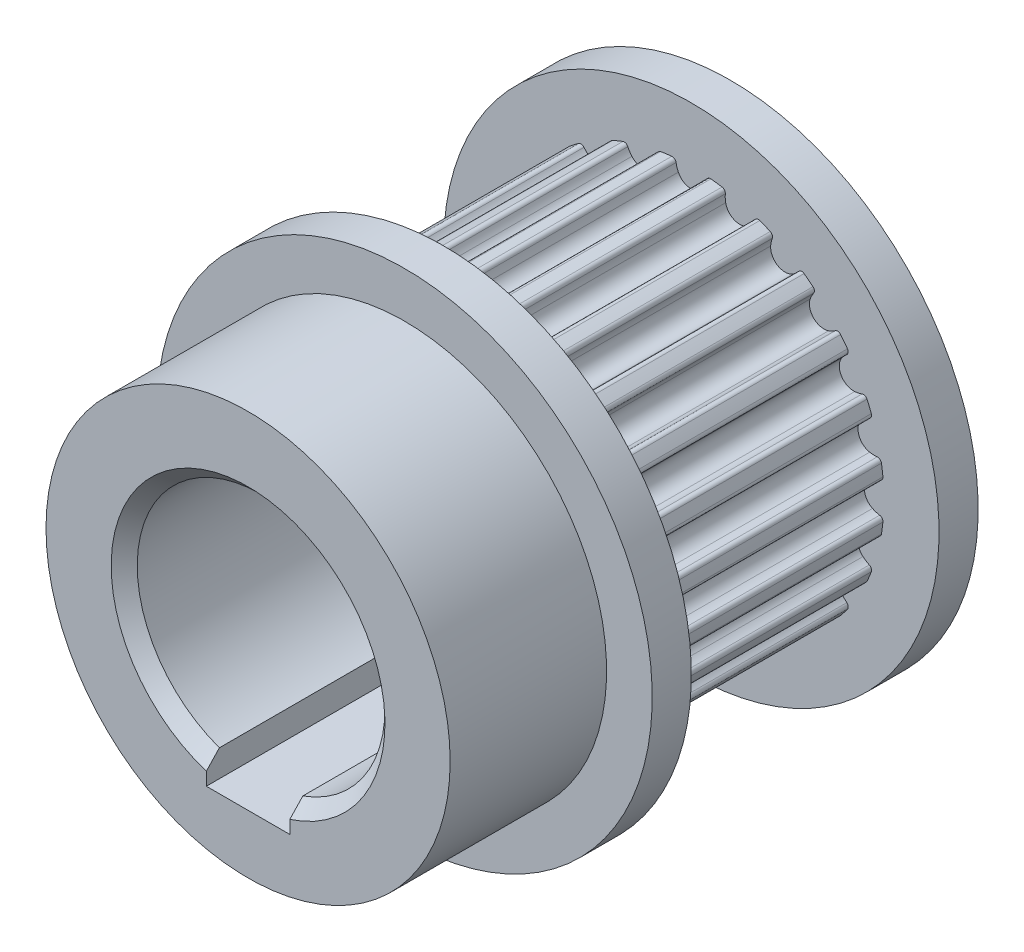
from build123d import *

# Parameters (mm, degrees)
BOSS_EXTRUDE1_DEPTH = 9.5
CUT_EXTRUDE1_DEPTH  = 9.5
SKETCH4_R           = 4.75
CUT_EXTRUDE2_DEPTH  = 15.079684088
SKETCH6_R           = 9.5
SKETCH6_R_2         = 4.75
BOSS_EXTRUDE2_DEPTH = 1.5
BOSS_EXTRUDE4_START = -9.5
SKETCH6_3_R         = 9.5
SKETCH6_3_R_2       = 4.75
BOSS_EXTRUDE4_DEPTH = 1.5
SKETCH7_R           = 7.75
SKETCH7_R_2         = 4.75
BOSS_EXTRUDE5_DEPTH = 6
SKETCH9_W           = 3.2
SKETCH9_H           = 5.5
CUT_EXTRUDE3_DEPTH  = 23.86372673
CHAMFER1_SIZE       = 0.5


with BuildPart() as part:
    # Sketch1 → Boss-Extrude1 (new body)
    with BuildSketch(Plane.XY):
        with BuildLine():
            ThreePointArc((-0.749859573, 7.347268932), (0, -7.385435), (0.749859573, 7.347268932))
            ThreePointArc((0.749859573, 7.347268932), (0.643529079, 7.317210656), (0.586634557, 7.222486386))
            ThreePointArc((0.586634557, 7.222486386), (0.55274815, 7.081673642), (0.498876404, 6.947232753))
            ThreePointArc((0.498876404, 6.947232753), (0, 6.635435), (-0.498876404, 6.947232753))
            ThreePointArc((-0.498876404, 6.947232753), (-0.55274815, 7.081673642), (-0.586634557, 7.222486386))
            ThreePointArc((-0.586634557, 7.222486386), (-0.643529079, 7.317210656), (-0.749859573, 7.347268932))
        make_face()
    extrude(amount=BOSS_EXTRUDE1_DEPTH)

    # Sketch2 → Cut-Extrude1 (cut)
    with BuildSketch(Plane.XY.offset(9.5)):
        with BuildLine():
            ThreePointArc((-1.30267156, 7.128218326), (-1.272232117, 7.234440331), (-1.177304402, 7.290994753))
            ThreePointArc((-1.177304402, 7.290994753), (-1.911491234, 7.133782405), (-2.625921857, 6.902838876))
            ThreePointArc((-2.625921857, 6.902838876), (-2.515434832, 6.901325167), (-2.435962499, 6.824553935))
            ThreePointArc((-2.435962499, 6.824553935), (-2.366785723, 6.697309716), (-2.27995375, 6.581392823))
            ThreePointArc((-2.27995375, 6.581392823), (-1.717376951, 6.409338035), (-1.316198544, 6.839630252))
            ThreePointArc((-1.316198544, 6.839630252), (-1.298958296, 6.983433212), (-1.30267156, 7.128218326))
        make_face()
        with BuildLine():
            ThreePointArc((2.625921857, 6.902838876), (1.911491234, 7.133782405), (1.177304402, 7.290994753))
            ThreePointArc((1.177304402, 7.290994753), (1.272232117, 7.234440331), (1.30267156, 7.128218326))
            ThreePointArc((1.30267156, 7.128218326), (1.298958296, 6.983433212), (1.316198544, 6.839630252))
            ThreePointArc((1.316198544, 6.839630252), (1.717376951, 6.409338035), (2.27995375, 6.581392823))
            ThreePointArc((2.27995375, 6.581392823), (2.366785723, 6.697309716), (2.435962499, 6.824553935))
            ThreePointArc((2.435962499, 6.824553935), (2.515434832, 6.901325167), (2.625921857, 6.902838876))
        make_face()
        with BuildLine():
            ThreePointArc((4.323031905, 5.987991757), (3.6927175, 6.395974328), (3.024237027, 6.73785133))
            ThreePointArc((3.024237027, 6.73785133), (3.101292798, 6.658654852), (3.103202764, 6.548173968))
            ThreePointArc((3.103202764, 6.548173968), (3.062142881, 6.40928335), (3.041576737, 6.265918252))
            ThreePointArc((3.041576737, 6.265918252), (3.3177175, 5.746455275), (3.905656016, 5.767041848))
            ThreePointArc((3.905656016, 5.767041848), (4.019530761, 5.8565352), (4.119283622, 5.96153941))
            ThreePointArc((4.119283622, 5.96153941), (4.215917859, 6.015125773), (4.323031905, 5.987991757))
        make_face()
        with BuildLine():
            ThreePointArc((5.725534474, 4.665072896), (5.222291171, 5.222291171), (4.665072896, 5.725534474))
            ThreePointArc((4.665072896, 5.725534474), (4.719005499, 5.62909305), (4.692255827, 5.521882374))
            ThreePointArc((4.692255827, 5.521882374), (4.616647489, 5.398351419), (4.559676501, 5.265194279))
            ThreePointArc((4.559676501, 5.265194279), (4.691961085, 4.691961085), (5.265194279, 4.559676501))
            ThreePointArc((5.265194279, 4.559676501), (5.398351419, 4.616647489), (5.521882374, 4.692255827))
            ThreePointArc((5.521882374, 4.692255827), (5.62909305, 4.719005499), (5.725534474, 4.665072896))
        make_face()
        with BuildLine():
            ThreePointArc((6.73785133, 3.024237027), (6.395974328, 3.6927175), (5.987991757, 4.323031905))
            ThreePointArc((5.987991757, 4.323031905), (6.015125773, 4.215917859), (5.96153941, 4.119283622))
            ThreePointArc((5.96153941, 4.119283622), (5.8565352, 4.019530761), (5.767041848, 3.905656016))
            ThreePointArc((5.767041848, 3.905656016), (5.746455275, 3.3177175), (6.265918252, 3.041576737))
            ThreePointArc((6.265918252, 3.041576737), (6.40928335, 3.062142881), (6.548173968, 3.103202764))
            ThreePointArc((6.548173968, 3.103202764), (6.658654852, 3.101292798), (6.73785133, 3.024237027))
        make_face()
        with BuildLine():
            ThreePointArc((7.290994753, 1.177304402), (7.133782405, 1.911491234), (6.902838876, 2.625921857))
            ThreePointArc((6.902838876, 2.625921857), (6.901325167, 2.515434832), (6.824553935, 2.435962499))
            ThreePointArc((6.824553935, 2.435962499), (6.697309716, 2.366785723), (6.581392823, 2.27995375))
            ThreePointArc((6.581392823, 2.27995375), (6.409338035, 1.717376951), (6.839630252, 1.316198544))
            ThreePointArc((6.839630252, 1.316198544), (6.983433212, 1.298958296), (7.128218326, 1.30267156))
            ThreePointArc((7.128218326, 1.30267156), (7.234440331, 1.272232117), (7.290994753, 1.177304402))
        make_face()
        with BuildLine():
            ThreePointArc((7.385435, 0), (7.375887312, 0.375415113), (7.347268932, 0.749859573))
            ThreePointArc((7.347268932, 0.749859573), (7.317210656, 0.643529079), (7.222486386, 0.586634557))
            ThreePointArc((7.222486386, 0.586634557), (7.081673642, 0.55274815), (6.947232753, 0.498876404))
            ThreePointArc((6.947232753, 0.498876404), (6.635435, 0), (6.947232753, -0.498876404))
            ThreePointArc((6.947232753, -0.498876404), (7.081673642, -0.55274815), (7.222486386, -0.586634557))
            ThreePointArc((7.222486386, -0.586634557), (7.317210656, -0.643529079), (7.347268932, -0.749859573))
            ThreePointArc((7.347268932, -0.749859573), (7.375887312, -0.375415113), (7.385435, 0))
        make_face()
        with BuildLine():
            ThreePointArc((6.902838876, -2.625921857), (7.133782405, -1.911491234), (7.290994753, -1.177304402))
            ThreePointArc((7.290994753, -1.177304402), (7.234440331, -1.272232117), (7.128218326, -1.30267156))
            ThreePointArc((7.128218326, -1.30267156), (6.983433212, -1.298958296), (6.839630252, -1.316198544))
            ThreePointArc((6.839630252, -1.316198544), (6.409338035, -1.717376951), (6.581392823, -2.27995375))
            ThreePointArc((6.581392823, -2.27995375), (6.697309716, -2.366785723), (6.824553935, -2.435962499))
            ThreePointArc((6.824553935, -2.435962499), (6.901325167, -2.515434832), (6.902838876, -2.625921857))
        make_face()
        with BuildLine():
            ThreePointArc((5.987991757, -4.323031905), (6.395974328, -3.6927175), (6.73785133, -3.024237027))
            ThreePointArc((6.73785133, -3.024237027), (6.658654852, -3.101292798), (6.548173968, -3.103202764))
            ThreePointArc((6.548173968, -3.103202764), (6.40928335, -3.062142881), (6.265918252, -3.041576737))
            ThreePointArc((6.265918252, -3.041576737), (5.746455275, -3.3177175), (5.767041848, -3.905656016))
            ThreePointArc((5.767041848, -3.905656016), (5.8565352, -4.019530761), (5.96153941, -4.119283622))
            ThreePointArc((5.96153941, -4.119283622), (6.015125773, -4.215917859), (5.987991757, -4.323031905))
        make_face()
        with BuildLine():
            ThreePointArc((4.665072896, -5.725534474), (5.222291171, -5.222291171), (5.725534474, -4.665072896))
            ThreePointArc((5.725534474, -4.665072896), (5.62909305, -4.719005499), (5.521882374, -4.692255827))
            ThreePointArc((5.521882374, -4.692255827), (5.398351419, -4.616647489), (5.265194279, -4.559676501))
            ThreePointArc((5.265194279, -4.559676501), (4.691961085, -4.691961085), (4.559676501, -5.265194279))
            ThreePointArc((4.559676501, -5.265194279), (4.616647489, -5.398351419), (4.692255827, -5.521882374))
            ThreePointArc((4.692255827, -5.521882374), (4.719005499, -5.62909305), (4.665072896, -5.725534474))
        make_face()
        with BuildLine():
            ThreePointArc((3.024237027, -6.73785133), (3.6927175, -6.395974328), (4.323031905, -5.987991757))
            ThreePointArc((4.323031905, -5.987991757), (4.215917859, -6.015125773), (4.119283622, -5.96153941))
            ThreePointArc((4.119283622, -5.96153941), (4.019530761, -5.8565352), (3.905656016, -5.767041848))
            ThreePointArc((3.905656016, -5.767041848), (3.3177175, -5.746455275), (3.041576737, -6.265918252))
            ThreePointArc((3.041576737, -6.265918252), (3.062142881, -6.40928335), (3.103202764, -6.548173968))
            ThreePointArc((3.103202764, -6.548173968), (3.101292798, -6.658654852), (3.024237027, -6.73785133))
        make_face()
        with BuildLine():
            ThreePointArc((1.177304402, -7.290994753), (1.911491234, -7.133782405), (2.625921857, -6.902838876))
            ThreePointArc((2.625921857, -6.902838876), (2.515434832, -6.901325167), (2.435962499, -6.824553935))
            ThreePointArc((2.435962499, -6.824553935), (2.366785723, -6.697309716), (2.27995375, -6.581392823))
            ThreePointArc((2.27995375, -6.581392823), (1.717376951, -6.409338035), (1.316198544, -6.839630252))
            ThreePointArc((1.316198544, -6.839630252), (1.298958296, -6.983433212), (1.30267156, -7.128218326))
            ThreePointArc((1.30267156, -7.128218326), (1.272232117, -7.234440331), (1.177304402, -7.290994753))
        make_face()
        with BuildLine():
            ThreePointArc((-0.586634557, -7.222486386), (-0.643529079, -7.317210656), (-0.749859573, -7.347268932))
            ThreePointArc((-0.749859573, -7.347268932), (0, -7.385435), (0.749859573, -7.347268932))
            ThreePointArc((0.749859573, -7.347268932), (0.643529079, -7.317210656), (0.586634557, -7.222486386))
            ThreePointArc((0.586634557, -7.222486386), (0.55274815, -7.081673642), (0.498876404, -6.947232753))
            ThreePointArc((0.498876404, -6.947232753), (0, -6.635435), (-0.498876404, -6.947232753))
            ThreePointArc((-0.498876404, -6.947232753), (-0.55274815, -7.081673642), (-0.586634557, -7.222486386))
        make_face()
        with BuildLine():
            ThreePointArc((-2.435962499, -6.824553935), (-2.515434832, -6.901325167), (-2.625921857, -6.902838876))
            ThreePointArc((-2.625921857, -6.902838876), (-1.911491234, -7.133782405), (-1.177304402, -7.290994753))
            ThreePointArc((-1.177304402, -7.290994753), (-1.272232117, -7.234440331), (-1.30267156, -7.128218326))
            ThreePointArc((-1.30267156, -7.128218326), (-1.298958296, -6.983433212), (-1.316198544, -6.839630252))
            ThreePointArc((-1.316198544, -6.839630252), (-1.717376951, -6.409338035), (-2.27995375, -6.581392823))
            ThreePointArc((-2.27995375, -6.581392823), (-2.366785723, -6.697309716), (-2.435962499, -6.824553935))
        make_face()
        with BuildLine():
            ThreePointArc((-4.119283622, -5.96153941), (-4.215917859, -6.015125773), (-4.323031905, -5.987991757))
            ThreePointArc((-4.323031905, -5.987991757), (-3.6927175, -6.395974328), (-3.024237027, -6.73785133))
            ThreePointArc((-3.024237027, -6.73785133), (-3.101292798, -6.658654852), (-3.103202764, -6.548173968))
            ThreePointArc((-3.103202764, -6.548173968), (-3.062142881, -6.40928335), (-3.041576737, -6.265918252))
            ThreePointArc((-3.041576737, -6.265918252), (-3.3177175, -5.746455275), (-3.905656016, -5.767041848))
            ThreePointArc((-3.905656016, -5.767041848), (-4.019530761, -5.8565352), (-4.119283622, -5.96153941))
        make_face()
        with BuildLine():
            ThreePointArc((-5.521882374, -4.692255827), (-5.62909305, -4.719005499), (-5.725534474, -4.665072896))
            ThreePointArc((-5.725534474, -4.665072896), (-5.222291171, -5.222291171), (-4.665072896, -5.725534474))
            ThreePointArc((-4.665072896, -5.725534474), (-4.719005499, -5.62909305), (-4.692255827, -5.521882374))
            ThreePointArc((-4.692255827, -5.521882374), (-4.616647489, -5.398351419), (-4.559676501, -5.265194279))
            ThreePointArc((-4.559676501, -5.265194279), (-4.691961085, -4.691961085), (-5.265194279, -4.559676501))
            ThreePointArc((-5.265194279, -4.559676501), (-5.398351419, -4.616647489), (-5.521882374, -4.692255827))
        make_face()
        with BuildLine():
            ThreePointArc((-6.548173968, -3.103202764), (-6.658654852, -3.101292798), (-6.73785133, -3.024237027))
            ThreePointArc((-6.73785133, -3.024237027), (-6.395974328, -3.6927175), (-5.987991757, -4.323031905))
            ThreePointArc((-5.987991757, -4.323031905), (-6.015125773, -4.215917859), (-5.96153941, -4.119283622))
            ThreePointArc((-5.96153941, -4.119283622), (-5.8565352, -4.019530761), (-5.767041848, -3.905656016))
            ThreePointArc((-5.767041848, -3.905656016), (-5.746455275, -3.3177175), (-6.265918252, -3.041576737))
            ThreePointArc((-6.265918252, -3.041576737), (-6.40928335, -3.062142881), (-6.548173968, -3.103202764))
        make_face()
        with BuildLine():
            ThreePointArc((-7.128218326, -1.30267156), (-7.234440331, -1.272232117), (-7.290994753, -1.177304402))
            ThreePointArc((-7.290994753, -1.177304402), (-7.133782405, -1.911491234), (-6.902838876, -2.625921857))
            ThreePointArc((-6.902838876, -2.625921857), (-6.901325167, -2.515434832), (-6.824553935, -2.435962499))
            ThreePointArc((-6.824553935, -2.435962499), (-6.697309716, -2.366785723), (-6.581392823, -2.27995375))
            ThreePointArc((-6.581392823, -2.27995375), (-6.409338035, -1.717376951), (-6.839630252, -1.316198544))
            ThreePointArc((-6.839630252, -1.316198544), (-6.983433212, -1.298958296), (-7.128218326, -1.30267156))
        make_face()
        with BuildLine():
            ThreePointArc((-7.222486386, 0.586634557), (-7.317210656, 0.643529079), (-7.347268932, 0.749859573))
            ThreePointArc((-7.347268932, 0.749859573), (-7.385435, 0), (-7.347268932, -0.749859573))
            ThreePointArc((-7.347268932, -0.749859573), (-7.317210656, -0.643529079), (-7.222486386, -0.586634557))
            ThreePointArc((-7.222486386, -0.586634557), (-7.081673642, -0.55274815), (-6.947232753, -0.498876404))
            ThreePointArc((-6.947232753, -0.498876404), (-6.635435, 0), (-6.947232753, 0.498876404))
            ThreePointArc((-6.947232753, 0.498876404), (-7.081673642, 0.55274815), (-7.222486386, 0.586634557))
        make_face()
        with BuildLine():
            ThreePointArc((-6.824553935, 2.435962499), (-6.901325167, 2.515434832), (-6.902838876, 2.625921857))
            ThreePointArc((-6.902838876, 2.625921857), (-7.133782405, 1.911491234), (-7.290994753, 1.177304402))
            ThreePointArc((-7.290994753, 1.177304402), (-7.234440331, 1.272232117), (-7.128218326, 1.30267156))
            ThreePointArc((-7.128218326, 1.30267156), (-6.983433212, 1.298958296), (-6.839630252, 1.316198544))
            ThreePointArc((-6.839630252, 1.316198544), (-6.409338035, 1.717376951), (-6.581392823, 2.27995375))
            ThreePointArc((-6.581392823, 2.27995375), (-6.697309716, 2.366785723), (-6.824553935, 2.435962499))
        make_face()
        with BuildLine():
            ThreePointArc((-5.96153941, 4.119283622), (-6.015125773, 4.215917859), (-5.987991757, 4.323031905))
            ThreePointArc((-5.987991757, 4.323031905), (-6.395974328, 3.6927175), (-6.73785133, 3.024237027))
            ThreePointArc((-6.73785133, 3.024237027), (-6.658654852, 3.101292798), (-6.548173968, 3.103202764))
            ThreePointArc((-6.548173968, 3.103202764), (-6.40928335, 3.062142881), (-6.265918252, 3.041576737))
            ThreePointArc((-6.265918252, 3.041576737), (-5.746455275, 3.3177175), (-5.767041848, 3.905656016))
            ThreePointArc((-5.767041848, 3.905656016), (-5.8565352, 4.019530761), (-5.96153941, 4.119283622))
        make_face()
        with BuildLine():
            ThreePointArc((-4.692255827, 5.521882374), (-4.719005499, 5.62909305), (-4.665072896, 5.725534474))
            ThreePointArc((-4.665072896, 5.725534474), (-5.222291171, 5.222291171), (-5.725534474, 4.665072896))
            ThreePointArc((-5.725534474, 4.665072896), (-5.62909305, 4.719005499), (-5.521882374, 4.692255827))
            ThreePointArc((-5.521882374, 4.692255827), (-5.398351419, 4.616647489), (-5.265194279, 4.559676501))
            ThreePointArc((-5.265194279, 4.559676501), (-4.691961085, 4.691961085), (-4.559676501, 5.265194279))
            ThreePointArc((-4.559676501, 5.265194279), (-4.616647489, 5.398351419), (-4.692255827, 5.521882374))
        make_face()
        with BuildLine():
            ThreePointArc((-3.103202764, 6.548173968), (-3.101292798, 6.658654852), (-3.024237027, 6.73785133))
            ThreePointArc((-3.024237027, 6.73785133), (-3.6927175, 6.395974328), (-4.323031905, 5.987991757))
            ThreePointArc((-4.323031905, 5.987991757), (-4.215917859, 6.015125773), (-4.119283622, 5.96153941))
            ThreePointArc((-4.119283622, 5.96153941), (-4.019530761, 5.8565352), (-3.905656016, 5.767041848))
            ThreePointArc((-3.905656016, 5.767041848), (-3.3177175, 5.746455275), (-3.041576737, 6.265918252))
            ThreePointArc((-3.041576737, 6.265918252), (-3.062142881, 6.40928335), (-3.103202764, 6.548173968))
        make_face()
    extrude(amount=-CUT_EXTRUDE1_DEPTH, mode=Mode.SUBTRACT)

    # Sketch4 → Cut-Extrude2 (cut, through all)
    with BuildSketch(Plane(origin=(0, 0, 0), x_dir=(-1, 0, 0), z_dir=(0, 0, -1))):
        Circle(SKETCH4_R)
    extrude(amount=-CUT_EXTRUDE2_DEPTH, mode=Mode.SUBTRACT)

    # Sketch6 → Boss-Extrude2 (add)
    with BuildSketch(Plane(origin=(0, 0, 0), x_dir=(-1, 0, 0), z_dir=(0, 0, -1))):
        Circle(SKETCH6_R)
        Circle(SKETCH6_R_2, mode=Mode.SUBTRACT)
    extrude(amount=BOSS_EXTRUDE2_DEPTH)

    # Sketch6_3 → Boss-Extrude4 (add)
    with BuildSketch(Plane(origin=(0, 0, 0), x_dir=(-1, 0, 0), z_dir=(0, 0, -1)).offset(BOSS_EXTRUDE4_START)):
        Circle(SKETCH6_3_R)
        Circle(SKETCH6_3_R_2, mode=Mode.SUBTRACT)
    extrude(amount=-BOSS_EXTRUDE4_DEPTH)

    # Sketch7 → Boss-Extrude5 (add)
    with BuildSketch(Plane.XY.offset(11)):
        with Locations(Location((0, 0, 0), (0, 0, 180))):
            Circle(SKETCH7_R)
        with Locations(Location((0, 0, 0), (0, 0, 180))):
            Circle(SKETCH7_R_2, mode=Mode.SUBTRACT)
    extrude(amount=BOSS_EXTRUDE5_DEPTH)

    # Sketch9 → Cut-Extrude3 (cut, through all)
    with BuildSketch(Plane.XY.offset(17)):
        with Locations((0, -2.75)):
            Rectangle(SKETCH9_W, SKETCH9_H)
    extrude(amount=-CUT_EXTRUDE3_DEPTH, mode=Mode.SUBTRACT)

    # Chamfer1
    chamfer1_edges = [part.edges().sort_by_distance(p)[0] for p in [
        (0, 4.75, 17),
        (0, 4.75, -1.5),
    ]]
    chamfer(chamfer1_edges, length=CHAMFER1_SIZE)


solid = part.part
